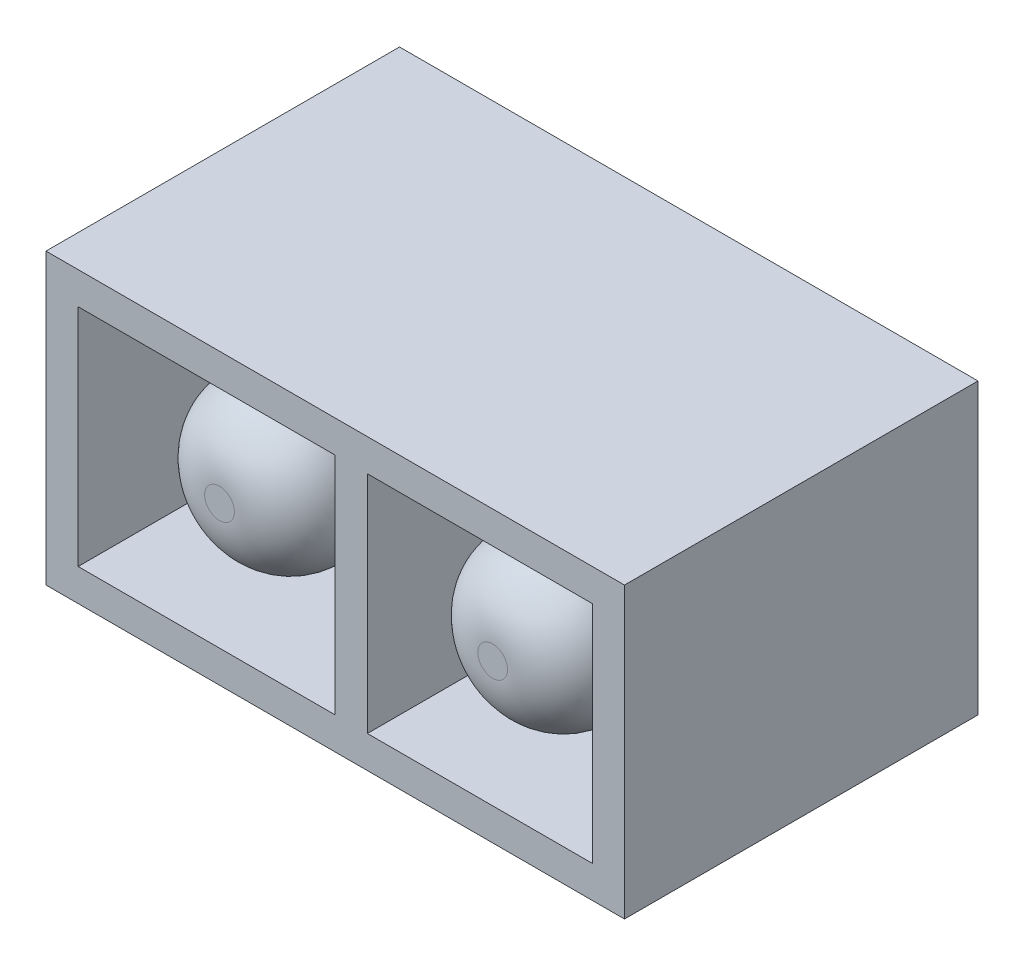
from build123d import *

# Parameters (mm, degrees)
SKETCH1_W             = 0.5
SKETCH1_H             = 4.5
EXTRUDE_THIN2_DEPTH   = 5
SKETCH1_W_2           = 9
SKETCH1_W_3           = 8
SKETCH1_H_2           = 3.5
EXTRUDE_THIN2_2_DEPTH = 5
SKETCH2_W             = 9
SKETCH2_H             = 4.5
BOSS_EXTRUDE1_DEPTH   = 0.5
SKETCH4_R             = 1.5
BOSS_EXTRUDE3_DEPTH   = 4.8
BOSS_EXTRUDE3_TAPER   = 4
FILLET1_R             = 1


with BuildPart() as part:
    # Sketch1 → Extrude-Thin2 (new body)
    with BuildSketch(Plane.XY):
        with Locations((0.25, 0)):
            Rectangle(SKETCH1_W, SKETCH1_H)
    extrude(amount=EXTRUDE_THIN2_DEPTH)



with BuildPart() as body_2:
    # Sketch1 → Extrude-Thin2 2 (new body)
    with BuildSketch(Plane.XY):
        Rectangle(SKETCH1_W_2, SKETCH1_H)
        Rectangle(SKETCH1_W_3, SKETCH1_H_2, mode=Mode.SUBTRACT)
    extrude(amount=EXTRUDE_THIN2_2_DEPTH)


with BuildPart() as part_1:
    add(part.part)

    add(body_2.part)  # Boss-Extrude1 merges body 2
    # Sketch2 → Boss-Extrude1 (add)
    with BuildSketch(Plane(origin=(0, 0, 0), x_dir=(-1, 0, 0), z_dir=(0, 0, -1))):
        Rectangle(SKETCH2_W, SKETCH2_H)
    extrude(amount=BOSS_EXTRUDE1_DEPTH)

    # Sketch4 → Boss-Extrude3 (add)
    with BuildSketch(Plane.XY):
        with Locations((2.25, 0)):
            Circle(SKETCH4_R)
        with Locations((-2, 0)):
            Circle(SKETCH4_R)
    extrude(amount=BOSS_EXTRUDE3_DEPTH, taper=BOSS_EXTRUDE3_TAPER)

    # Fillet1
    fillet1_edges = [part_1.edges().sort_by_distance(p)[0] for p in [
        (1.085648697, 0, 4.8),
        (-3.164351303, 0, 4.8),
    ]]
    fillet(fillet1_edges, radius=FILLET1_R)


solid = part_1.part
